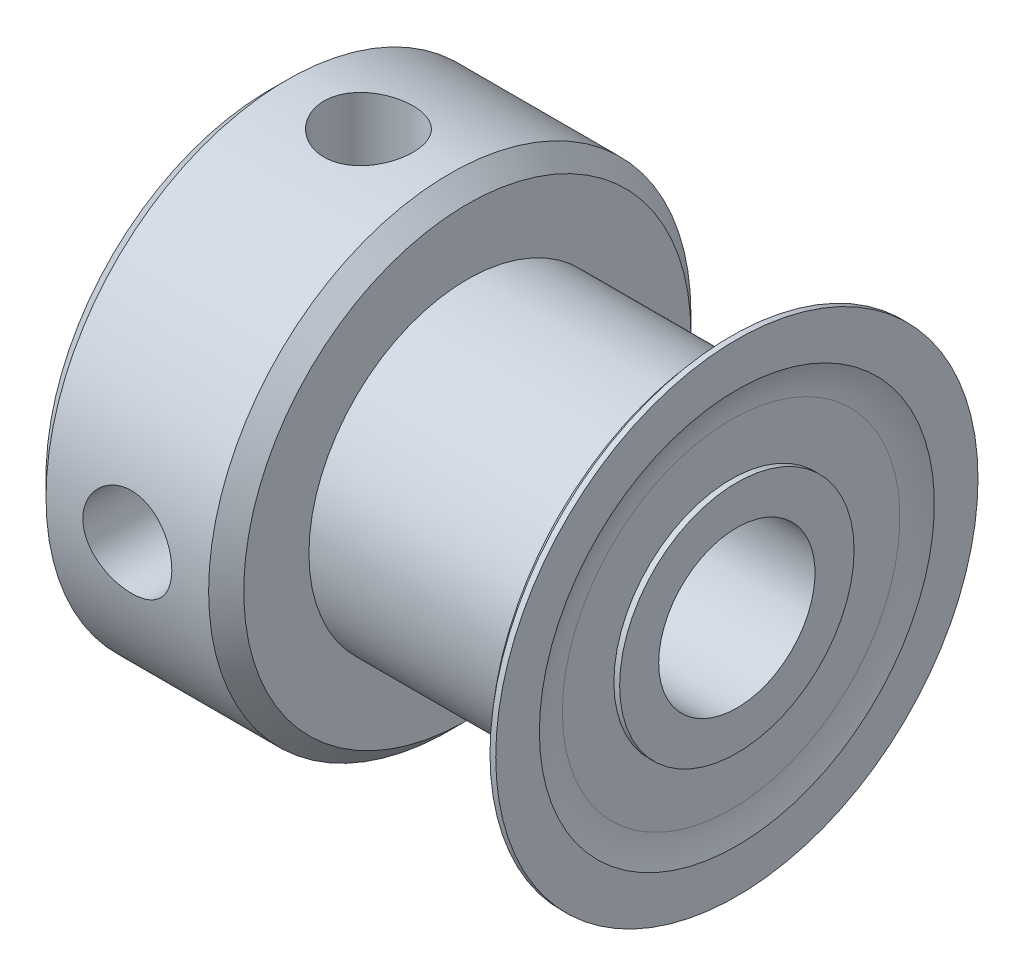
from build123d import *

# Parameters (mm, degrees)
SKETCH5_R         = 1.3589
SET_SCREWS_DEPTH  = 10
CIRPATTERN1_COUNT = 2
CIRPATTERN1_ANGLE = 90


with BuildPart() as part:
    # Sketch2 → Base Body (revolve)
    with BuildSketch(Plane.XY):
        Polygon((-7.1374, 2.3876), (7.1374, 2.3876), (7.1374, 3.5814), (6.06679, 3.5814), (6.06679, 4.8387), (-1.09601, 4.8387), (-1.09601, 3.5814), (-7.1374, 3.5814), align=None)
    revolve(axis=Axis((-7.1374, 0, 0), (1, 0, 0)))


with BuildPart() as body_2:
    # Sketch3 → Hub (revolve)
    with BuildSketch(Plane(origin=(0, 0, 0), x_dir=(1, 0, 0), z_dir=(0, 1, 0))):
        Polygon((-1.09601, 3.5814), (-7.1374, 3.5814), (-7.1374, 6.82879), (-6.60019, 7.366), (-1.63322, 7.366), (-1.09601, 6.82879), align=None)
    revolve(axis=Axis((0, 0, 0), (-1, 0, 0)))


with BuildPart() as body_3:
    # Sketch4 → Flange (revolve)
    with BuildSketch(Plane(origin=(0, 0, 0), x_dir=(1, 0, 0), z_dir=(0, 1, 0))):
        with BuildLine():
            Line((6.06679, 3.5814), (6.06679, 5.1562))
            ThreePointArc((6.06679, 5.1562), (6.299092689, 6.34832312), (6.962007344, 7.366))
            Line((6.962007344, 7.366), (7.1374, 7.366))
            Line((7.1374, 7.366), (7.1374, 6.033098904))
            ThreePointArc((7.1374, 6.033098904), (7.006285495, 5.603333725), (6.962007344, 5.1562))
            Line((6.962007344, 5.1562), (6.962007344, 3.5814))
            Line((6.962007344, 3.5814), (6.06679, 3.5814))
        make_face()
    revolve(axis=Axis((0, 0, 0), (1, 0, 0)))


with BuildPart() as set_screws_tool:
    # Sketch5 → Set Screws (new body)
    with BuildSketch(Plane(origin=(0, 0, 0), x_dir=(1, 0, 0), z_dir=(0, 1, 0))):
        with Locations((-4.116705, 0)):
            Circle(SKETCH5_R)
    set_screws = extrude(amount=SET_SCREWS_DEPTH)


with BuildPart() as part_1:
    add(part.part)

    # Set Screws: cut by set_screws_tool
    add(set_screws_tool.part, mode=Mode.SUBTRACT)


with BuildPart() as body_2_1:
    add(body_2.part)

    # Set Screws: cut by set_screws_tool
    add(set_screws_tool.part, mode=Mode.SUBTRACT)


with BuildPart() as cirpattern1_tool:
    # CirPattern1: Set Screws ×2 about axis
    cirpattern1_axis = Axis((-7.1374, 0, 0), (1, 0, 0))
    for i in range(1, CIRPATTERN1_COUNT):
        add(set_screws.rotate(cirpattern1_axis, i * CIRPATTERN1_ANGLE / (CIRPATTERN1_COUNT - 1)))


with BuildPart() as part_2:
    add(part_1.part)

    # CirPattern1: cut by cirpattern1_tool
    add(cirpattern1_tool.part, mode=Mode.SUBTRACT)


with BuildPart() as body_2_2:
    add(body_2_1.part)

    # CirPattern1: cut by cirpattern1_tool
    add(cirpattern1_tool.part, mode=Mode.SUBTRACT)


solid = Compound([body_3.part, part_2.part, body_2_2.part])
